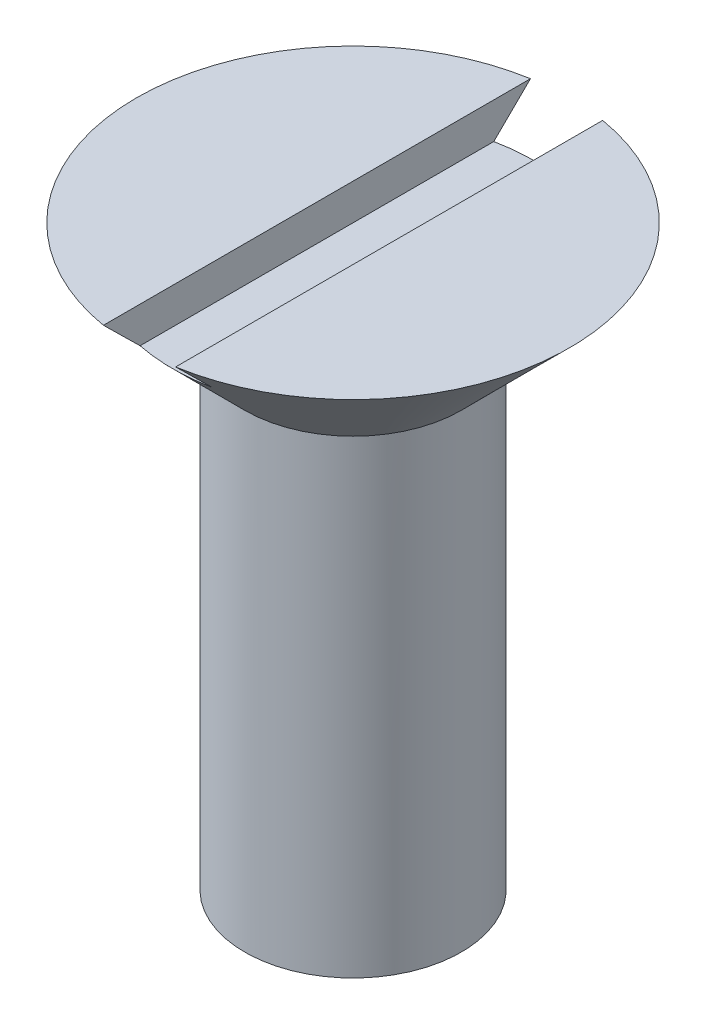
from build123d import *

# Parameters (mm, degrees)
SKETCH2_R           = 3
BOSS_EXTRUDE1_DEPTH = 6.5
SKETCH7_W           = 2
SKETCH7_H           = 1
CUT_EXTRUDE1_DEPTH  = 7


with BuildPart() as part:
    # Sketch2 → Boss-Extrude1 (new body, symmetric)
    with BuildSketch(Plane(origin=(0, 0, 0), x_dir=(1, 0, 0), z_dir=(0, 1, 0))):
        Circle(SKETCH2_R)
    extrude(amount=BOSS_EXTRUDE1_DEPTH, both=True)

    # Sketch5 → Revolve2 (revolve)
    with BuildSketch(Plane.XY):
        Polygon((-3, -6.5), (0, -8.232050808), (0, -6.5), align=None)
    revolve(axis=Axis((0, -6.5, 0), (0, -1, 0)))

    # Sketch6 → Revolve3 (revolve)
    with BuildSketch(Plane.XY):
        Polygon((3, 6.5), (0, 6.5), (0, 9.5), (6, 9.5), align=None)
    revolve(axis=Axis((0, 6.5, 0), (0, 1, 0)))

    # Sketch7 → Cut-Extrude1 (cut, symmetric)
    with BuildSketch(Plane.XY):
        with Locations((0, 9)):
            Rectangle(SKETCH7_W, SKETCH7_H)
    extrude(amount=CUT_EXTRUDE1_DEPTH, both=True, mode=Mode.SUBTRACT)


solid = part.part
